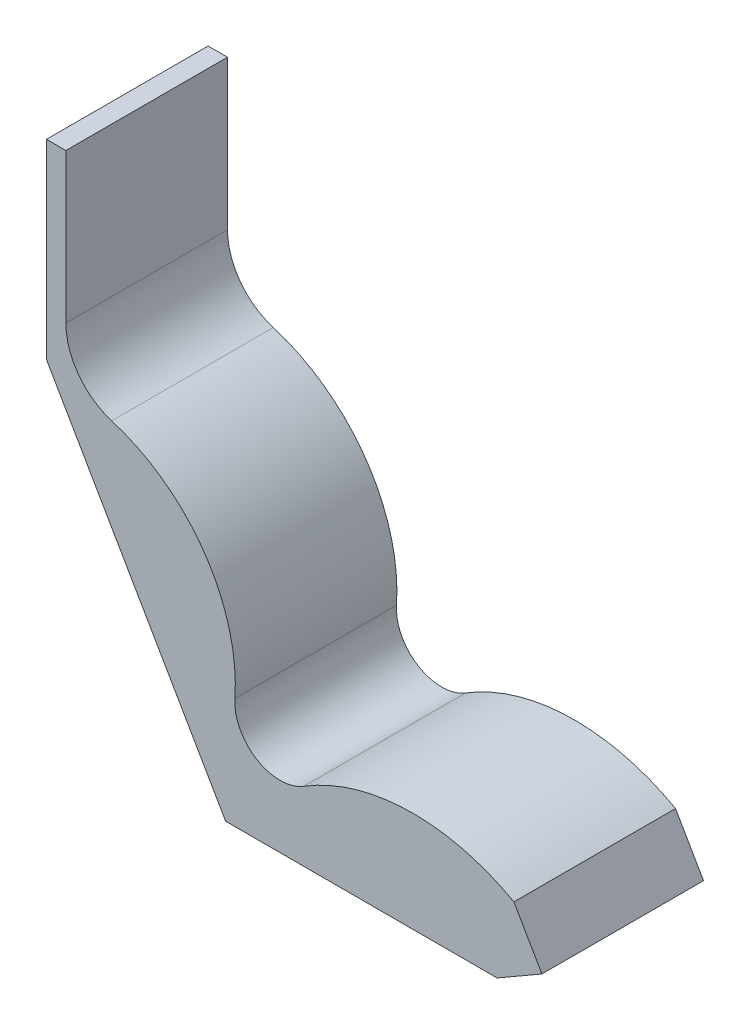
from build123d import *

# Parameters (mm, degrees)
BOSS_EXTRUDE1_DEPTH = 250


with BuildPart() as part:
    # Sketch2 → Boss-Extrude1 (new body)
    with BuildSketch(Plane.XY):
        with BuildLine():
            Line((-277.128129211, 480), (0, 0))
            Line((0, 0), (420, 0))
            Line((420, 0), (489.282032303, 40))
            Line((489.282032303, 40), (445.980762114, 115))
            ThreePointArc((445.980762114, 115), (282.530694349, 155.502719239), (121.149011162, 107.415847331))
            ThreePointArc((121.149011162, 107.415847331), (48.13293846, 106.892445498), (14.374916134, 171.638231083))
            ThreePointArc((14.374916134, 171.638231083), (-32.686291511, 343.220804781), (-176.282688884, 448.270371763))
            ThreePointArc((-176.282688884, 448.270371763), (-227.488119154, 484.4090757), (-247.128129211, 543.926065009))
            Line((-247.128129211, 543.926065009), (-247.128129211, 775))
            Line((-247.128129211, 775), (-277.128129211, 775))
            Line((-277.128129211, 775), (-277.128129211, 480))
        make_face()
    extrude(amount=BOSS_EXTRUDE1_DEPTH)


solid = part.part
